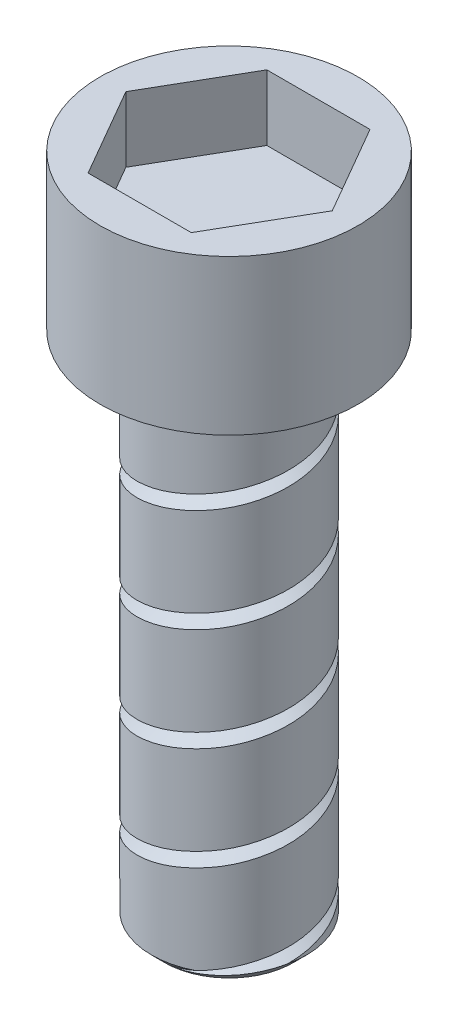
from build123d import *

# Parameters (mm, degrees)
SKETCH1_R           = 1.5
BOSS_EXTRUDE1_DEPTH = 10
SKETCH2_R           = 2.5
BOSS_EXTRUDE2_DEPTH = 3
CUT_EXTRUDE2_DEPTH  = 1.27
CHAMFER1_SIZE       = 0.254
CUT_SWEEP4_PITCH    = 2
CUT_SWEEP4_HEIGHT   = 9.04
CUT_SWEEP4_RADIUS   = 1.259947043


with BuildPart() as part:
    # Sketch1 → Boss-Extrude1 (new body)
    with BuildSketch(Plane(origin=(0, 0, 0), x_dir=(1, 0, 0), z_dir=(0, 1, 0))):
        Circle(SKETCH1_R)
    extrude(amount=BOSS_EXTRUDE1_DEPTH)

    # Sketch2 → Boss-Extrude2 (add)
    with BuildSketch(Plane(origin=(0, 10, 0), x_dir=(-1, 0, 0), z_dir=(0, 1, 0))):
        Circle(SKETCH2_R)
    extrude(amount=BOSS_EXTRUDE2_DEPTH)

    # Sketch3 → Cut-Extrude2 (cut)
    with BuildSketch(Plane(origin=(0, 13, 0), x_dir=(1, 0, 0), z_dir=(0, 1, 0))):
        Polygon((2.000485358, 0), (1.000242679, 1.73247114), (-1.000242679, 1.73247114), (-2.000485358, 0), (-1.000242679, -1.73247114), (1.000242679, -1.73247114), align=None)
    extrude(amount=-CUT_EXTRUDE2_DEPTH, mode=Mode.SUBTRACT)

    # Chamfer1
    chamfer1_edges = [part.edges().sort_by_distance(p)[0] for p in [
        (-1.5, 0, 0),
    ]]
    chamfer(chamfer1_edges, length=CHAMFER1_SIZE)

    # Cut-Sweep4: sweep along a helix
    with BuildLine() as cut_sweep4_path:
        Helix(CUT_SWEEP4_PITCH, CUT_SWEEP4_HEIGHT, CUT_SWEEP4_RADIUS, center=(0, 0, 0), direction=(0, 1, 0))
    # Sketch6 → Cut-Sweep4 (sweep, cut)
    with BuildSketch(Plane(origin=(0, 0, 0), x_dir=(0, 0, -1), z_dir=(1, 0, 0))):
        Polygon((-1.263842547, 0), (-2.577025719, 0.570115155), (-2.41416834, -0.852192409), align=None)
    sweep(path=cut_sweep4_path.line, is_frenet=True, mode=Mode.SUBTRACT)


solid = part.part
